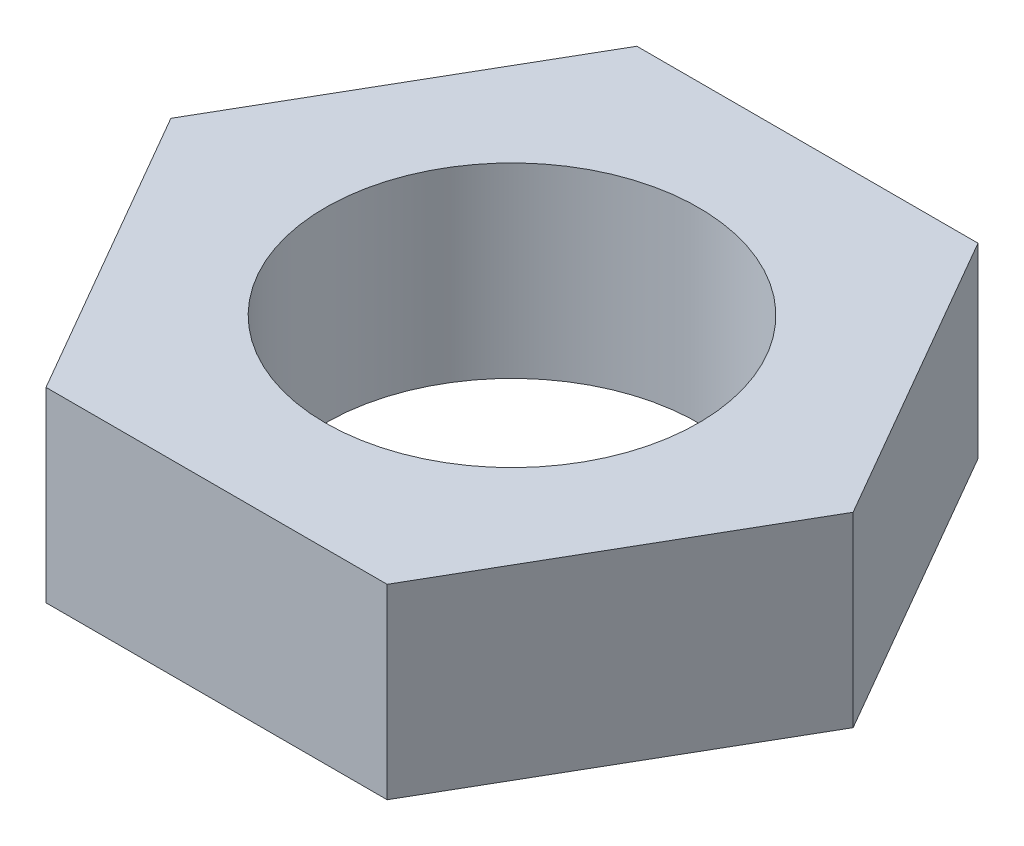
from build123d import *

# Parameters (mm, degrees)
BOSS_EXTRUDE1_DEPTH = 6
SKETCH2_R           = 6
CUT_EXTRUDE1_DEPTH  = 6


with BuildPart() as part:
    # Sketch1 → Boss-Extrude1 (new body)
    with BuildSketch(Plane(origin=(0, 0, 0), x_dir=(1, 0, 0), z_dir=(0, 1, 0))):
        Polygon((10.969655115, 0), (5.484827557, 9.5), (-5.484827557, 9.5), (-10.969655115, 0), (-5.484827557, -9.5), (5.484827557, -9.5), align=None)
    extrude(amount=-BOSS_EXTRUDE1_DEPTH)

    # Sketch2 → Cut-Extrude1 (cut)
    with BuildSketch(Plane(origin=(0, 0, 0), x_dir=(1, 0, 0), z_dir=(0, 1, 0))):
        Circle(SKETCH2_R)
    extrude(amount=-CUT_EXTRUDE1_DEPTH, mode=Mode.SUBTRACT)


solid = part.part
